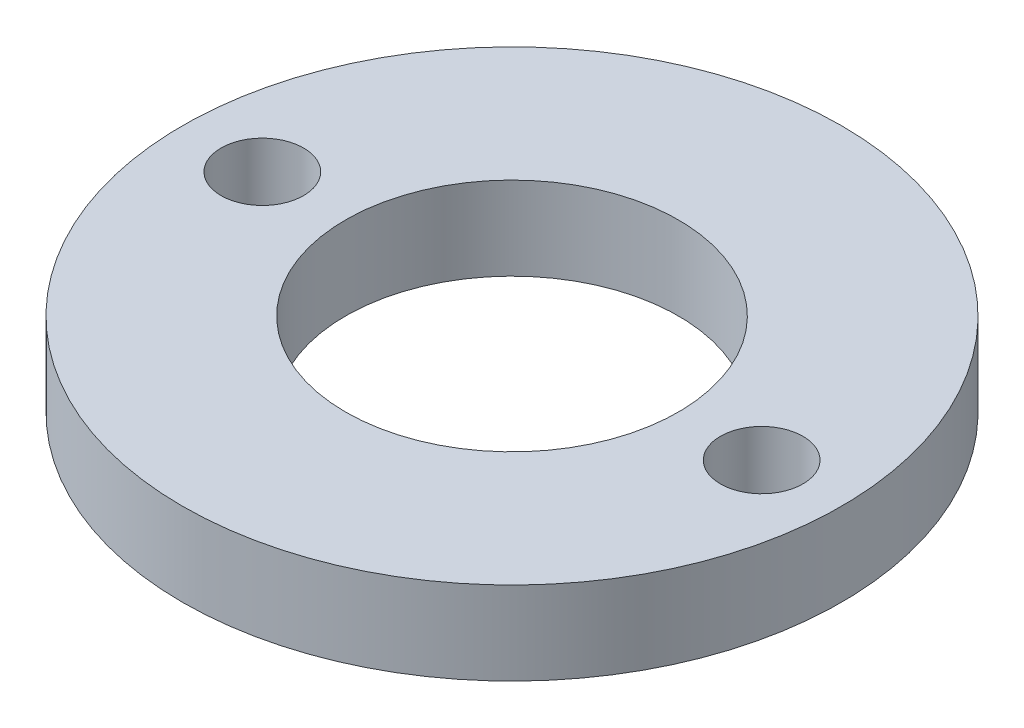
from build123d import *

# Parameters (mm, degrees)
SKETCH1_R           = 12.573
SKETCH1_R_2         = 6.35
BOSS_EXTRUDE1_DEPTH = 3.175
SKETCH2_R           = 1.575
CUT_EXTRUDE1_DEPTH  = 4.175


with BuildPart() as part:
    # Sketch1 → Boss-Extrude1 (new body)
    with BuildSketch(Plane(origin=(0, 0, 0), x_dir=(1, 0, 0), z_dir=(0, 1, 0))):
        Circle(SKETCH1_R)
        Circle(SKETCH1_R_2, mode=Mode.SUBTRACT)
    extrude(amount=BOSS_EXTRUDE1_DEPTH)

    # Sketch2 → Cut-Extrude1 (cut, through all)
    with BuildSketch(Plane(origin=(0, 3.175, 0), x_dir=(1, 0, 0), z_dir=(0, 1, 0))):
        with Locations((9.525, 0)):
            Circle(SKETCH2_R)
        with Locations((-9.525, 0)):
            Circle(SKETCH2_R)
    extrude(amount=-CUT_EXTRUDE1_DEPTH, mode=Mode.SUBTRACT)


solid = part.part
